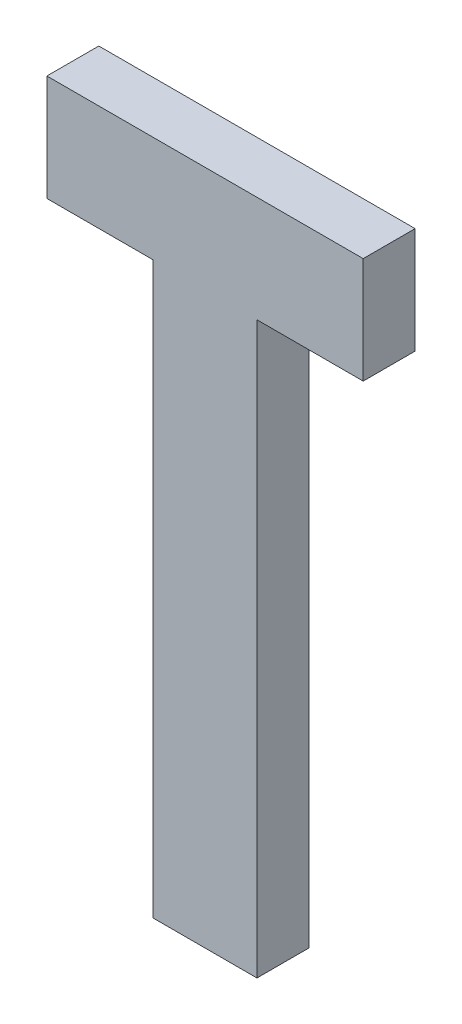
from build123d import *

# Parameters (mm, degrees)
BOSS_EXTRUDE2_DEPTH = 5


with BuildPart() as part:
    # Sketch2 → Boss-Extrude2 (new body)
    with BuildSketch(Plane.XY):
        Polygon((5, 24.891407059), (15.229503171, 24.891407059), (15.229503171, 35.108592941), (-15.229503171, 35.108592941), (-15.229503171, 24.891407059), (-5, 24.891407059), (-5, -30), (5, -30), align=None)
    extrude(amount=BOSS_EXTRUDE2_DEPTH)


solid = part.part
